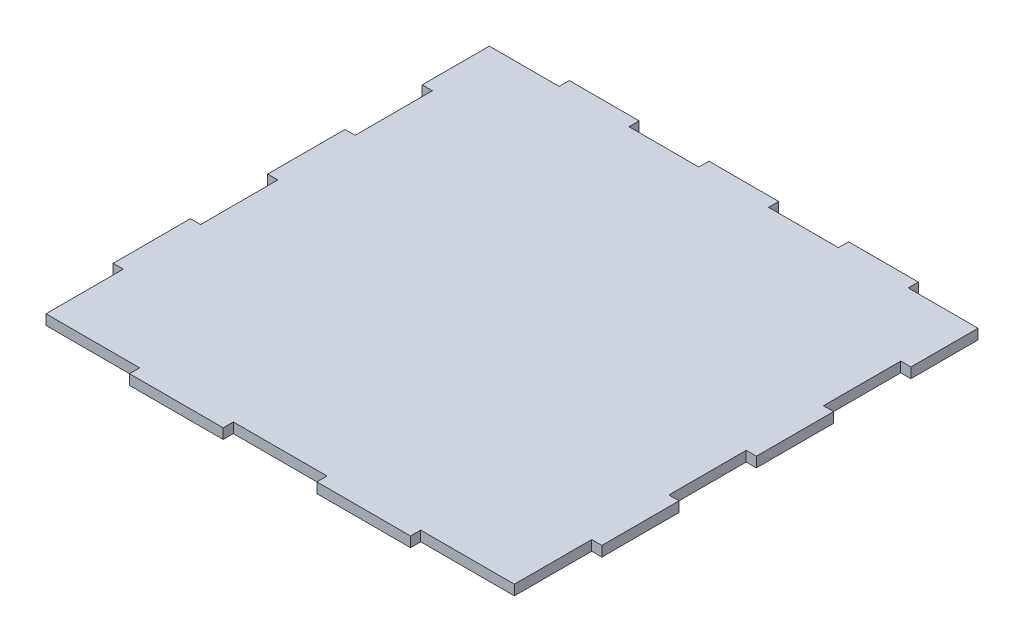
from build123d import *

# Parameters (mm, degrees)
BOSS_EXTRUDE1_DEPTH = 3
SKETCH4_W           = 144.4
SKETCH4_H           = 3
CUT_EXTRUDE1_DEPTH  = 4
SKETCH5_W           = 20.628571
SKETCH5_H           = 3
BOSS_EXTRUDE2_DEPTH = 3


with BuildPart() as part:
    # Sketch2 → Boss-Extrude1 (new body)
    with BuildSketch(Plane(origin=(0, 0, 0), x_dir=(1, 0, 0), z_dir=(0, 1, 0))):
        Polygon((-69.2, -68.5), (-41.52, -68.5), (-41.52, -71.5), (-13.84, -71.5), (-13.84, -68.5), (13.84, -68.5), (13.84, -71.5), (41.52, -71.5), (41.52, -68.5), (69.2, -68.5), (69.2, -45.653333333), (72.2, -45.653333333), (72.2, -22.823333333), (69.2, -22.823333333), (69.2, 0.006666667), (72.2, 0.006666667), (72.2, 22.836666667), (69.2, 22.836666667), (69.2, 45.666666667), (72.2, 45.666666667), (72.2, 68.5), (-72.2, 68.5), (-72.2, 45.666666667), (-69.2, 45.666666667), (-69.2, 22.836666667), (-72.2, 22.836666667), (-72.2, 0.006666667), (-69.2, 0.006666667), (-69.2, -22.823333333), (-72.2, -22.823333333), (-72.2, -45.653333333), (-69.2, -45.653333333), align=None)
    extrude(amount=BOSS_EXTRUDE1_DEPTH)

    # Sketch4 → Cut-Extrude1 (cut, through all)
    with BuildSketch(Plane.XZ):
        with Locations((0, -67)):
            Rectangle(SKETCH4_W, SKETCH4_H)
    extrude(amount=-CUT_EXTRUDE1_DEPTH, mode=Mode.SUBTRACT)

    # Sketch5 → Boss-Extrude2 (add)
    with BuildSketch(Plane.XZ):
        with Locations((-41.257143071, -67)):
            Rectangle(SKETCH5_W, SKETCH5_H)
        with Locations((-1.071e-06, -67)):
            Rectangle(SKETCH5_W, SKETCH5_H)
        with Locations((41.257140929, -67)):
            Rectangle(SKETCH5_W, SKETCH5_H)
    extrude(amount=-BOSS_EXTRUDE2_DEPTH)


solid = part.part
